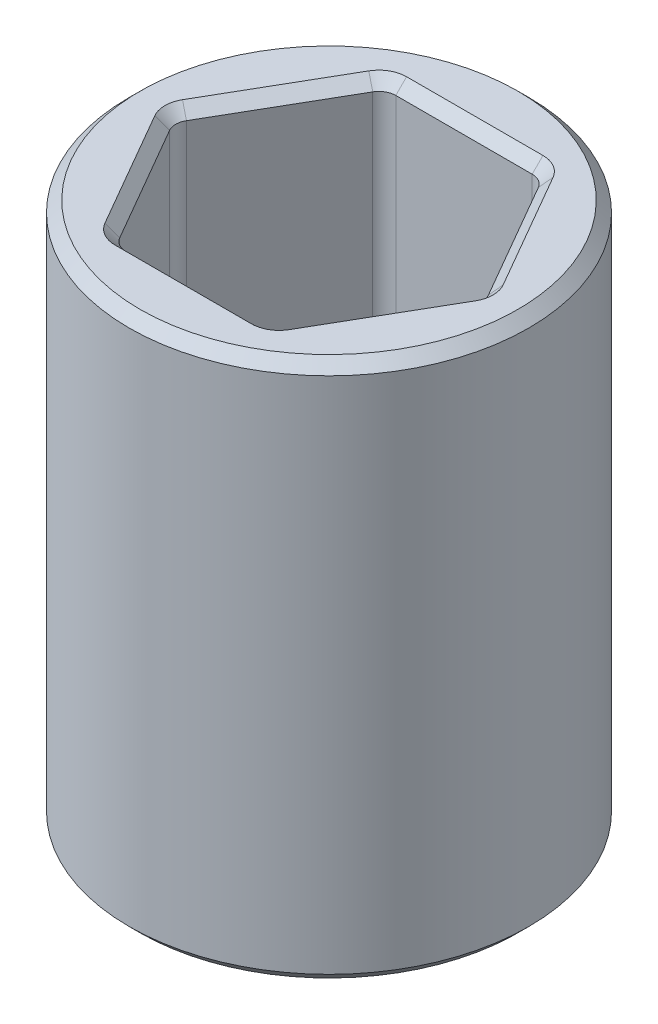
from build123d import *

# Parameters (mm, degrees)
SKETCH4_R           = 4.699
SKETCH4_R_2         = 1.5875
BOSS_EXTRUDE1_DEPTH = 12.7
CUT_EXTRUDE3_DEPTH  = 3.175
CUT_EXTRUDE2_START  = -6.35
CUT_EXTRUDE2_DEPTH  = 6.35
FILLET1_1_64_R      = 0.396875
CHAMFER1_SIZE       = 0.254


with BuildPart() as part:
    # Sketch4 → Boss-Extrude1 (new body)
    with BuildSketch(Plane(origin=(0, 0, 0), x_dir=(1, 0, 0), z_dir=(0, 1, 0))):
        Circle(SKETCH4_R)
        Circle(SKETCH4_R_2, mode=Mode.SUBTRACT)
    extrude(amount=BOSS_EXTRUDE1_DEPTH)

    # Sketch7 → Cut-Extrude3 (cut)
    with BuildSketch(Plane.XZ):
        Polygon((1.649778394, 2.8575), (-1.649778394, 2.8575), (-3.299556788, 0), (-1.649778394, -2.8575), (1.649778394, -2.8575), (3.299556788, 0), align=None)
    extrude(amount=-CUT_EXTRUDE3_DEPTH, mode=Mode.SUBTRACT)

    # Sketch6 → Cut-Extrude2 (cut)
    with BuildSketch(Plane(origin=(0, 12.7, 0), x_dir=(1, 0, 0), z_dir=(0, 1, 0)).offset(CUT_EXTRUDE2_START)):
        Polygon((1.833087105, 3.175), (-1.833087105, 3.175), (-3.666174209, 0), (-1.833087105, -3.175), (1.833087105, -3.175), (3.666174209, 0), align=None)
    extrude(amount=CUT_EXTRUDE2_DEPTH, mode=Mode.SUBTRACT)

    # Fillet1-1/64
    fillet1_1_64_edges = [part.edges().sort_by_distance(p)[0] for p in [
        (2.474667591, 3.175, 1.42875),
        (1.649778394, 1.5875, 2.8575),
        (2.474667591, 3.175, -1.42875),
        (3.299556788, 1.5875, 0),
        (0, 3.175, -2.8575),
        (1.649778394, 1.5875, -2.8575),
        (-2.474667591, 3.175, -1.42875),
        (-1.649778394, 1.5875, -2.8575),
        (-2.474667591, 3.175, 1.42875),
        (-3.299556788, 1.5875, 0),
        (0, 3.175, 2.8575),
        (-1.649778394, 1.5875, 2.8575),
        (0, 6.35, -3.175),
        (-1.833087105, 9.525, -3.175),
        (-2.749630657, 6.35, -1.5875),
        (-3.666174209, 9.525, 0),
        (-2.749630657, 6.35, 1.5875),
        (-1.833087105, 9.525, 3.175),
        (0, 6.35, 3.175),
        (1.833087105, 9.525, 3.175),
        (2.749630657, 6.35, 1.5875),
        (3.666174209, 9.525, 0),
        (2.749630657, 6.35, -1.5875),
        (1.833087105, 9.525, -3.175),
    ]]
    fillet(fillet1_1_64_edges, radius=FILLET1_1_64_R)

    # Chamfer1
    chamfer1_edges = [part.edges().sort_by_distance(p)[0] for p in [
        (-1.5875, 3.175, 0),
        (-4.699, 0, 0),
        (-1.5875, 6.35, 0),
        (-4.699, 12.7, 0),
        (-2.749630657, 12.7, 1.5875),
        (0, 12.7, 3.175),
        (2.749630657, 12.7, 1.5875),
        (2.749630657, 12.7, -1.5875),
        (0, 12.7, -3.175),
        (-2.749630657, 12.7, -1.5875),
        (0, 0, 2.8575),
        (-2.474667591, 0, 1.42875),
        (-2.474667591, 0, -1.42875),
        (0, 0, -2.8575),
        (2.474667591, 0, -1.42875),
        (2.474667591, 0, 1.42875),
        (-3.604777433, 12.7, 0),
        (-1.802388717, 12.7, 3.121828832),
        (1.802388717, 12.7, 3.121828832),
        (3.604777433, 12.7, 0),
        (1.802388717, 12.7, -3.121828832),
        (-1.802388717, 12.7, -3.121828832),
        (-1.619080006, 0, 2.804328832),
        (-3.238160012, 0, 0),
        (-1.619080006, 0, -2.804328832),
        (1.619080006, 0, -2.804328832),
        (3.238160012, 0, 0),
        (1.619080006, 0, 2.804328832),
    ]]
    chamfer(chamfer1_edges, length=CHAMFER1_SIZE)


solid = part.part
